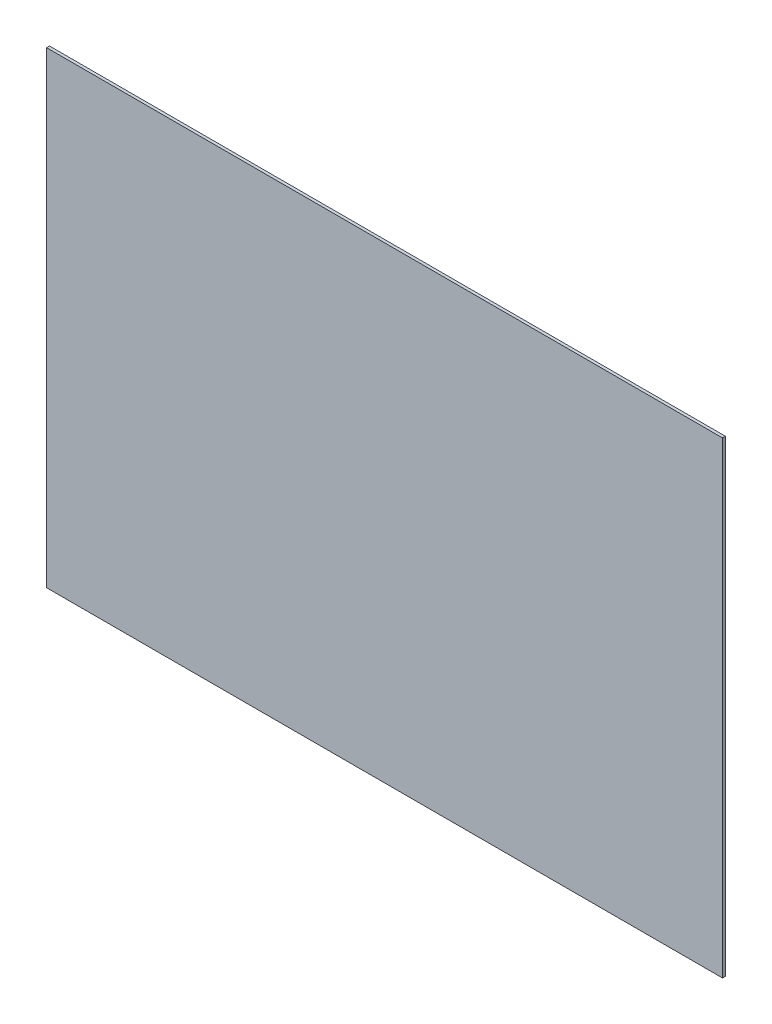
from build123d import *

# Parameters (mm, degrees)
SKETCH1_W           = 745
SKETCH1_H           = 515.6
BOSS_EXTRUDE1_DEPTH = 3.175


with BuildPart() as part:
    # Sketch1 → Boss-Extrude1 (new body)
    with BuildSketch(Plane.XY):
        Rectangle(SKETCH1_W, SKETCH1_H)
    extrude(amount=BOSS_EXTRUDE1_DEPTH)


solid = part.part
